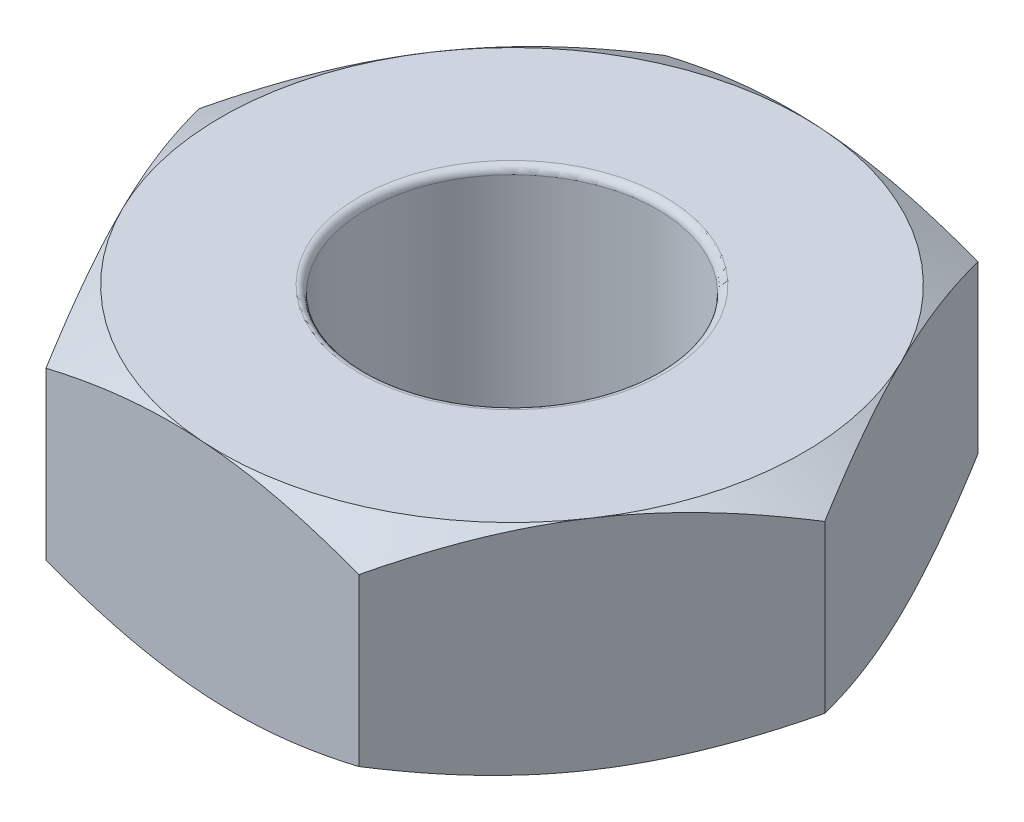
from build123d import *

# Parameters (mm, degrees)
SKETCH1_R           = 1
BOSS_EXTRUDE1_DEPTH = 1.5
SKETCH2_OUTSIDE_W   = 14.812
SKETCH2_OUTSIDE_H   = 14.348
SKETCH2_OUTSIDE_R   = 2
CUT_EXTRUDE1_DEPTH  = 2
CUT_EXTRUDE1_TAPER  = 60
SKETCH3_OUTSIDE_W   = 14.812
SKETCH3_OUTSIDE_H   = 14.348
SKETCH3_OUTSIDE_R   = 2
CUT_EXTRUDE2_DEPTH  = 2
CUT_EXTRUDE2_TAPER  = 60
FILLET1_R           = 0.05


with BuildPart() as part:
    # Sketch1 → Boss-Extrude1 (new body)
    with BuildSketch(Plane(origin=(0, 0, 0), x_dir=(1, 0, 0), z_dir=(0, 1, 0))):
        Polygon((-2.304270274, 0.153856556), (-1.285378822, -1.918628316), (1.018891451, -2.072484872), (2.304270274, -0.153856556), (1.285378822, 1.918628316), (-1.018891451, 2.072484872), align=None)
        Circle(SKETCH1_R, mode=Mode.SUBTRACT)
    extrude(amount=BOSS_EXTRUDE1_DEPTH)

    # Sketch2 outside → Cut-Extrude1 (cut)
    with BuildSketch(Plane(origin=(0, 1.5, 0), x_dir=(1, 0, 0), z_dir=(0, 1, 0))):
        Rectangle(SKETCH2_OUTSIDE_W, SKETCH2_OUTSIDE_H)
        Circle(SKETCH2_OUTSIDE_R, mode=Mode.SUBTRACT)
    extrude(amount=-CUT_EXTRUDE1_DEPTH, taper=CUT_EXTRUDE1_TAPER, mode=Mode.SUBTRACT)

    # Sketch3 outside → Cut-Extrude2 (cut)
    with BuildSketch(Plane.XZ):
        Rectangle(SKETCH3_OUTSIDE_W, SKETCH3_OUTSIDE_H)
        Circle(SKETCH3_OUTSIDE_R, mode=Mode.SUBTRACT)
    extrude(amount=-CUT_EXTRUDE2_DEPTH, taper=CUT_EXTRUDE2_TAPER, mode=Mode.SUBTRACT)

    # Fillet1
    fillet1_edges = [part.edges().sort_by_distance(p)[0] for p in [
        (-1, 0, 0),
        (-1, 1.5, 0),
    ]]
    fillet(fillet1_edges, radius=FILLET1_R)


solid = part.part
